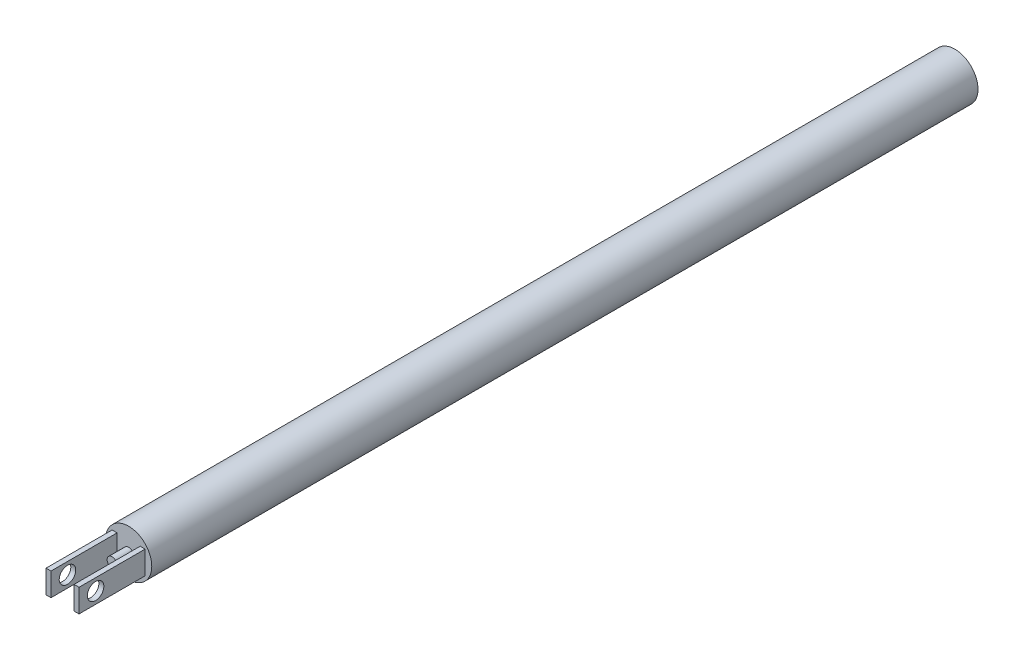
from build123d import *

# Parameters (mm, degrees)
SKETCH1_R                = 7
BOSS_EXTRUDE1_DEPTH      = 125
BOSS_EXTRUDE1_DEPTH_BACK = 125
SKETCH2_W                = 20
SKETCH2_H                = 7
SKETCH2_R                = 2.5
BOSS_EXTRUDE2_DEPTH      = 5
BOSS_EXTRUDE2_DEPTH_BACK = 5
SKETCH4_W                = 7
SKETCH4_H                = 7
CUT_EXTRUDE1_DEPTH       = 20
SKETCH5_R                = 1.5
BOSS_EXTRUDE3_DEPTH      = 5


with BuildPart() as part:
    # Sketch1 → Boss-Extrude1 (new body, two sides)
    with BuildSketch(Plane.XY) as boss_extrude1_sk:
        Circle(SKETCH1_R)
    extrude(amount=BOSS_EXTRUDE1_DEPTH)
    extrude(boss_extrude1_sk.sketch, amount=-BOSS_EXTRUDE1_DEPTH_BACK)

    # Sketch2 → Boss-Extrude2 (add, two sides)
    with BuildSketch(Plane(origin=(0, 0, 0), x_dir=(0, 0, -1), z_dir=(1, 0, 0))) as boss_extrude2_sk:
        with Locations((-135, 0)):
            Rectangle(SKETCH2_W, SKETCH2_H)
        with Locations((-140, 0)):
            Circle(SKETCH2_R, mode=Mode.SUBTRACT)
    extrude(amount=BOSS_EXTRUDE2_DEPTH)
    extrude(boss_extrude2_sk.sketch, amount=-BOSS_EXTRUDE2_DEPTH_BACK)

    # Sketch4 → Cut-Extrude1 (cut)
    with BuildSketch(Plane.XY.offset(145)):
        Rectangle(SKETCH4_W, SKETCH4_H)
    extrude(amount=-CUT_EXTRUDE1_DEPTH, mode=Mode.SUBTRACT)

    # Sketch5 → Boss-Extrude3 (add)
    with BuildSketch(Plane.XY.offset(125)):
        Circle(SKETCH5_R)
    extrude(amount=BOSS_EXTRUDE3_DEPTH)


solid = part.part
